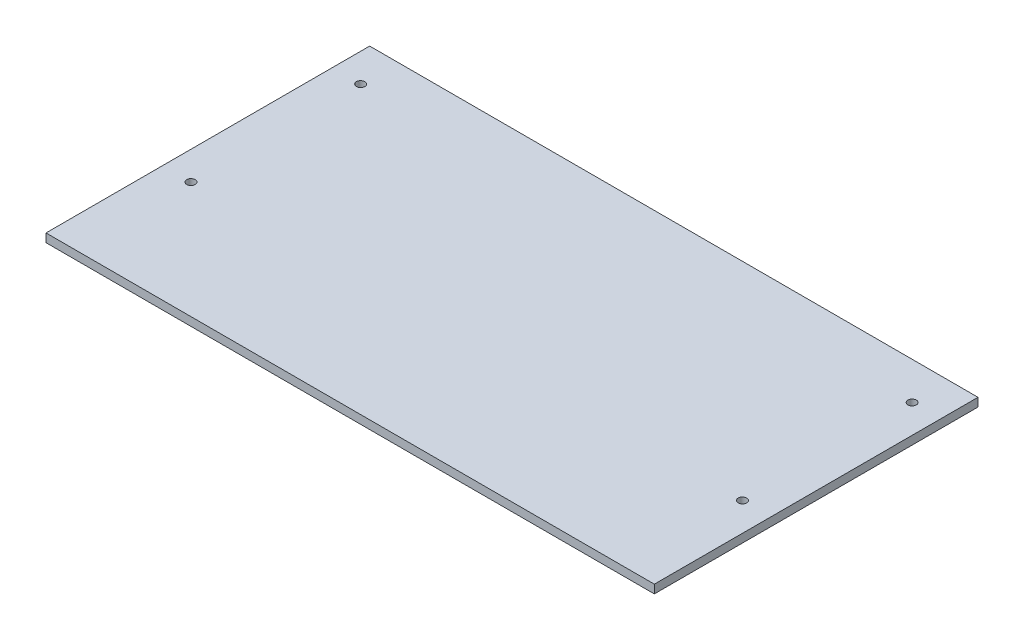
from build123d import *

# Parameters (mm, degrees)
CROQUIS1_W              = 215.09
CROQUIS1_H              = 114.4357103
CROQUIS1_R              = 1.5
SALIENTE_EXTRUIR1_DEPTH = 3


with BuildPart() as part:
    # Croquis1 → Saliente-Extruir1 (new body)
    with BuildSketch(Plane(origin=(0, 0, 0), x_dir=(1, 0, 0), z_dir=(0, 1, 0))):
        with Locations((0, 33.094498199)):
            Rectangle(CROQUIS1_W, CROQUIS1_H)
        with Locations((-97.495, 77.072708333)):
            Circle(CROQUIS1_R, mode=Mode.SUBTRACT)
        with Locations((97.495, 77.072708333)):
            Circle(CROQUIS1_R, mode=Mode.SUBTRACT)
        with Locations((-97.495, 17.072708333)):
            Circle(CROQUIS1_R, mode=Mode.SUBTRACT)
        with Locations((97.495, 17.072708333)):
            Circle(CROQUIS1_R, mode=Mode.SUBTRACT)
    extrude(amount=SALIENTE_EXTRUIR1_DEPTH)


solid = part.part
